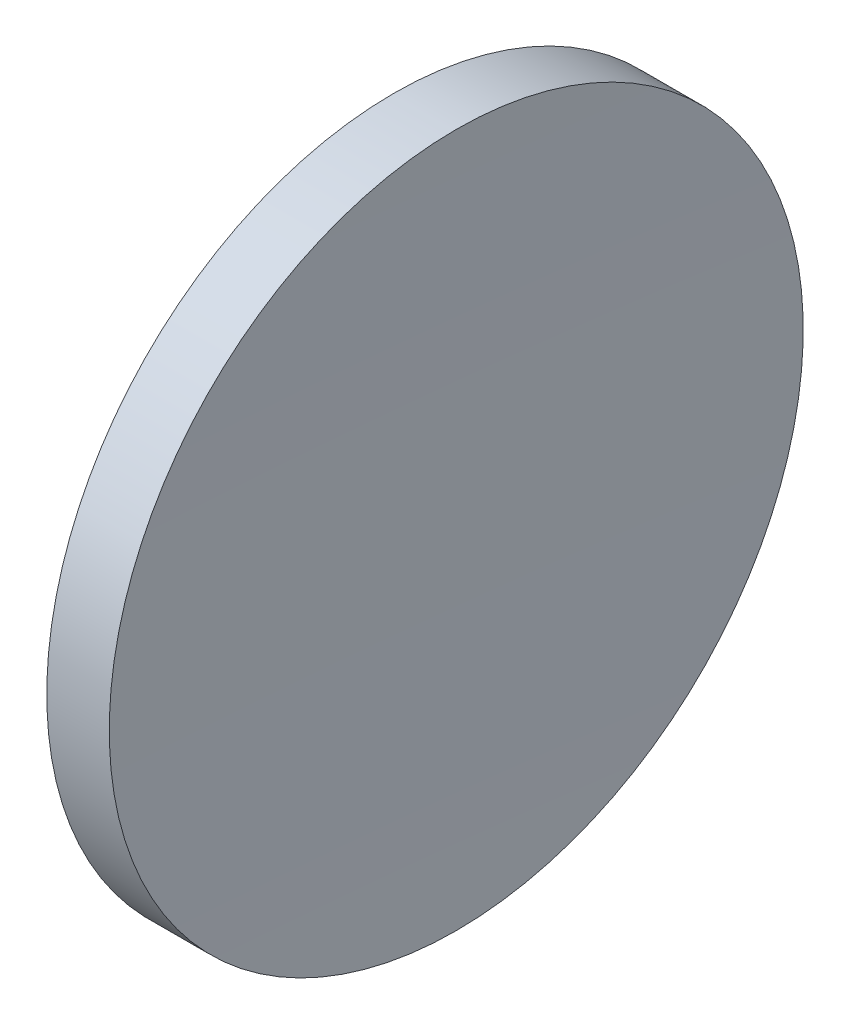
from build123d import *


with BuildPart() as part:
    # 草图1 → 旋转1 (revolve)
    with BuildSketch(Plane.XY):
        with BuildLine():
            Line((95.090443592, 52.178082298), (97.090444345, 52.178082298))
            ThreePointArc((97.090444345, 52.178082298), (97.126349746, 58.528488306), (97.234061355, 64.878082298))
            Line((97.234061355, 64.878082298), (96.090443968, 64.878082298))
            Line((96.090443968, 64.878082298), (94.946826581, 64.878082298))
            ThreePointArc((94.946826581, 64.878082298), (95.054538191, 58.528488306), (95.090443592, 52.178082298))
        make_face()
    revolve(axis=Axis((89.858656454, 52.178082298, 0), (1, 0, 0)))


solid = part.part
